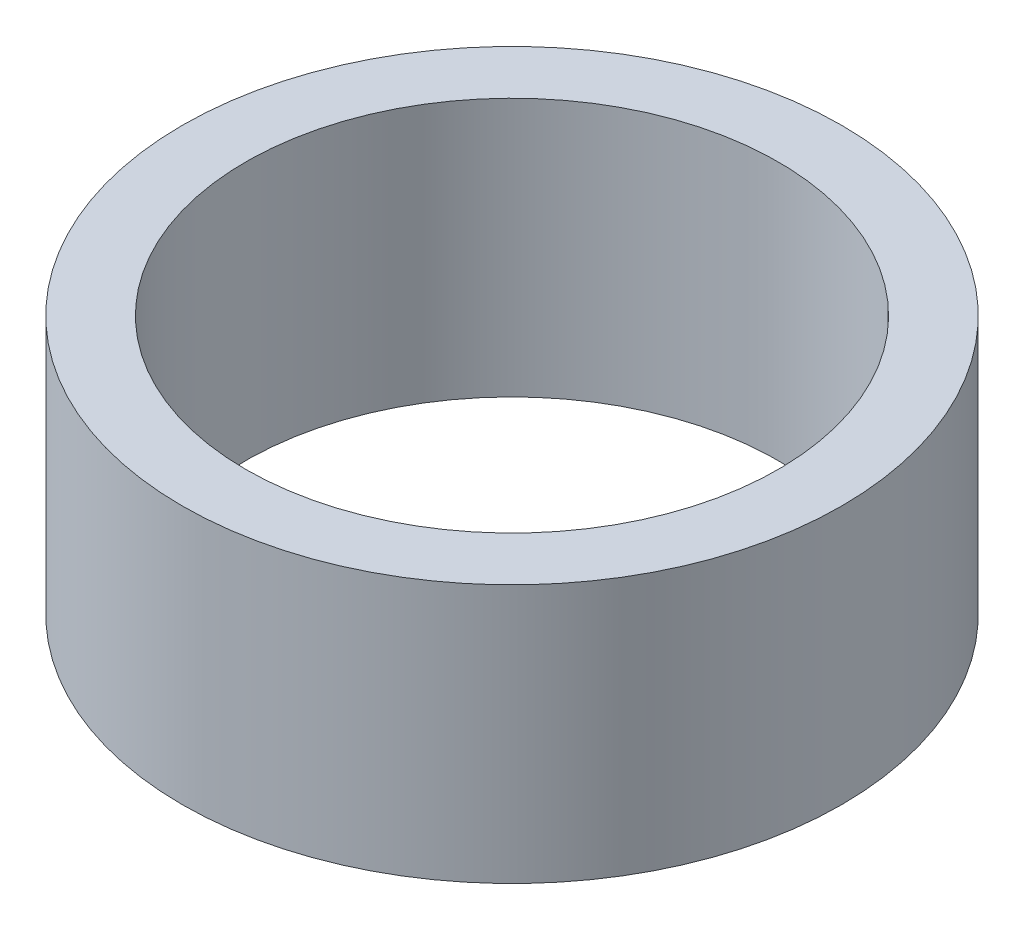
from build123d import *

# Parameters (mm, degrees)
SKETCH1_R           = 65
SKETCH1_R_2         = 52.5
BOSS_EXTRUDE1_DEPTH = 51


with BuildPart() as part:
    # Sketch1 → Boss-Extrude1 (new body)
    with BuildSketch(Plane(origin=(0, 0, 0), x_dir=(1, 0, 0), z_dir=(0, 1, 0))):
        Circle(SKETCH1_R)
        Circle(SKETCH1_R_2, mode=Mode.SUBTRACT)
    extrude(amount=BOSS_EXTRUDE1_DEPTH)


solid = part.part
